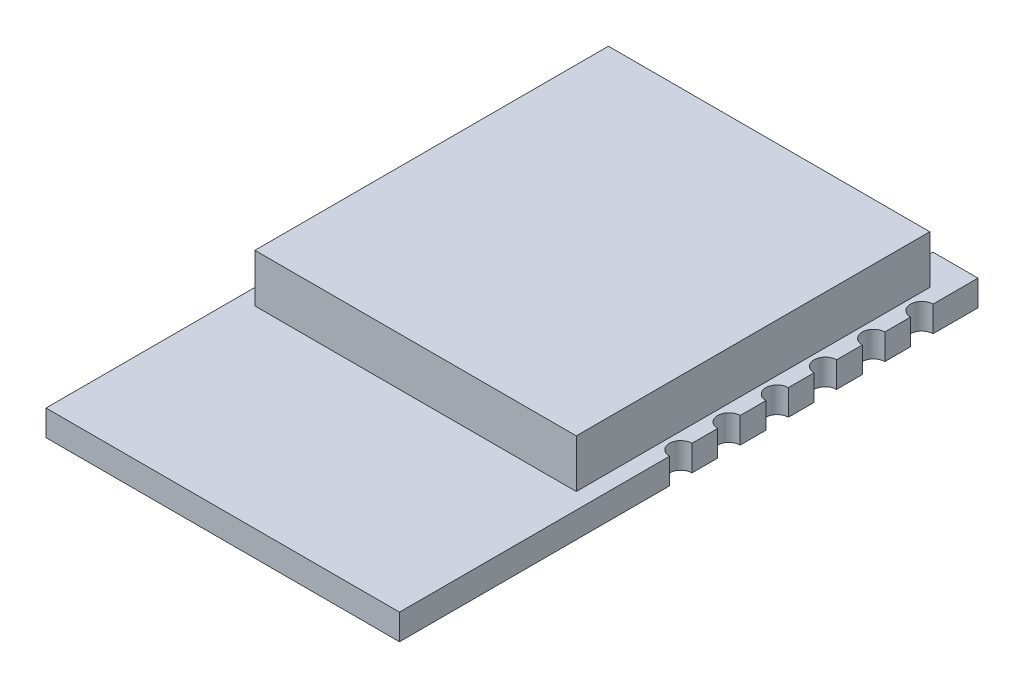
from build123d import *

# Parameters (mm, degrees)
SKETCH_2_W               = 11
SKETCH_2_H               = 18
EXTRUDE_1_DEPTH          = 0.8
SKETCH_3_W               = 10
SKETCH_3_H               = 11
EXTRUDE_3_DEPTH          = 2.3
SKETCH_7_R               = 0.35
CUT_EXTRUDE_1_DEPTH      = 2.3
SKETCH_9_R               = 0.35
CUT_EXTRUDE_2_DEPTH      = 2.3
CUT_EXTRUDE_2_DEPTH_BACK = 2.3
SKETCH_10_R              = 0.35
CUT_EXTRUDE_5_DEPTH      = 2.3
CUT_EXTRUDE_5_DEPTH_BACK = 2.3


with BuildPart() as part:
    # 草图2 → 凸台-拉伸1 (new body)
    with BuildSketch(Plane(origin=(0, 0, 0), x_dir=(1, 0, 0), z_dir=(0, 1, 0))):
        Rectangle(SKETCH_2_W, SKETCH_2_H)
    extrude(amount=EXTRUDE_1_DEPTH)

    # 草图3 → 凸台-拉伸3 (add)
    with BuildSketch(Plane(origin=(0, 0, 0), x_dir=(1, 0, 0), z_dir=(0, 1, 0))):
        with Locations((0, 2.5)):
            Rectangle(SKETCH_3_W, SKETCH_3_H)
    extrude(amount=EXTRUDE_3_DEPTH)

    # 草图7 → 切除-拉伸1 (cut)
    with BuildSketch(Plane(origin=(0, 0.8, 0), x_dir=(1, 0, 0), z_dir=(0, 1, 0))):
        with Locations((-3.75, 9)):
            Circle(SKETCH_7_R)
    extrude(amount=-CUT_EXTRUDE_1_DEPTH, mode=Mode.SUBTRACT)

    # 草图9 → 切除-拉伸2 (cut, two sides)
    with BuildSketch(Plane(origin=(0, 0, 0), x_dir=(1, 0, 0), z_dir=(0, 1, 0))) as cut_extrude_2_sk:
        with Locations((-2.25, 9)):
            Circle(SKETCH_9_R)
        with Locations((-0.75, 9)):
            Circle(SKETCH_9_R)
        with Locations((0.75, 9)):
            Circle(SKETCH_9_R)
        with Locations((3.75, 9)):
            Circle(SKETCH_9_R)
        with Locations((2.25, 9)):
            Circle(SKETCH_9_R)
    extrude(amount=CUT_EXTRUDE_2_DEPTH, mode=Mode.SUBTRACT)
    extrude(cut_extrude_2_sk.sketch, amount=-CUT_EXTRUDE_2_DEPTH_BACK, mode=Mode.SUBTRACT)

    # 草图10 → 切除-拉伸5 (cut, two sides)
    with BuildSketch(Plane(origin=(0, 0, 0), x_dir=(1, 0, 0), z_dir=(0, 1, 0))) as cut_extrude_5_sk:
        with Locations((-5.5, 7.25)):
            Circle(SKETCH_10_R)
        with Locations((5.5, 7.25)):
            Circle(SKETCH_10_R)
        with Locations((5.5, -0.25)):
            Circle(SKETCH_10_R)
        with Locations((-5.5, 2.75)):
            Circle(SKETCH_10_R)
        with Locations((5.5, 5.75)):
            Circle(SKETCH_10_R)
        with Locations((-5.5, 4.25)):
            Circle(SKETCH_10_R)
        with Locations((5.5, 2.75)):
            Circle(SKETCH_10_R)
        with Locations((-5.5, 5.75)):
            Circle(SKETCH_10_R)
        with Locations((5.5, 4.25)):
            Circle(SKETCH_10_R)
        with Locations((5.5, 1.25)):
            Circle(SKETCH_10_R)
        with Locations((-5.5, 1.25)):
            Circle(SKETCH_10_R)
        with Locations((-5.5, -0.25)):
            Circle(SKETCH_10_R)
    extrude(amount=CUT_EXTRUDE_5_DEPTH, mode=Mode.SUBTRACT)
    extrude(cut_extrude_5_sk.sketch, amount=-CUT_EXTRUDE_5_DEPTH_BACK, mode=Mode.SUBTRACT)


solid = part.part
